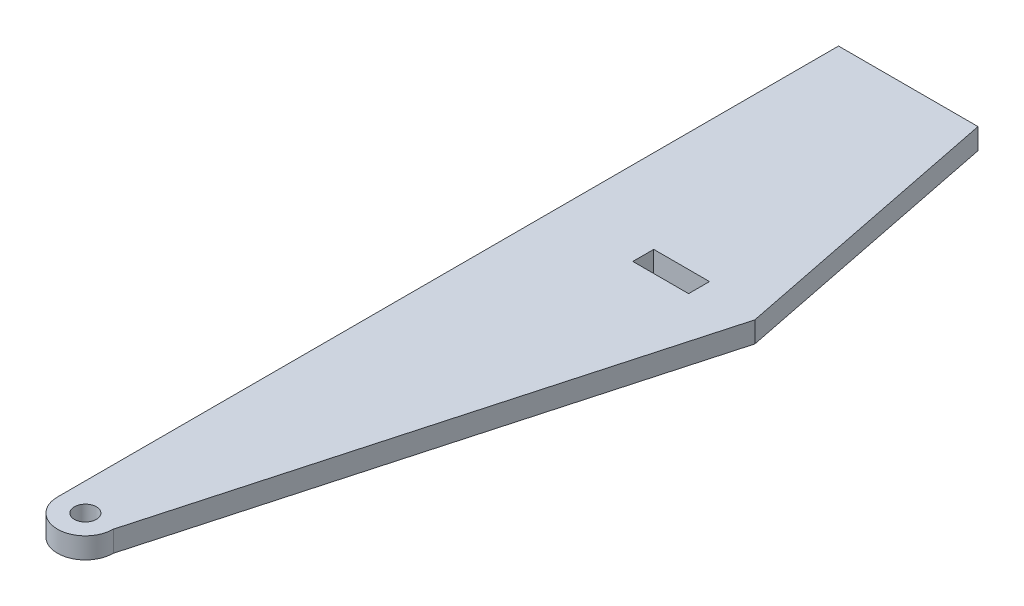
from build123d import *

# Parameters (mm, degrees)
SKETCH1_R           = 10
SKETCH1_W           = 50.8
SKETCH1_H           = 19.05
BOSS_EXTRUDE1_DEPTH = 19.05


with BuildPart() as part:
    # Sketch1 → Boss-Extrude1 (new body)
    with BuildSketch(Plane(origin=(0, 0, 0), x_dir=(1, 0, 0), z_dir=(0, 1, 0))):
        with BuildLine():
            Line((-25.4, 0), (-25.4, 711.2))
            Line((-25.4, 711.2), (101.6, 711.2))
            Line((101.6, 711.2), (152.4, 457.2))
            Line((152.4, 457.2), (25.4, 0))
            ThreePointArc((25.4, 0), (0, -25.4), (-25.4, 0))
        make_face()
        Circle(SKETCH1_R, mode=Mode.SUBTRACT)
        with Locations((76.2, 457.2)):
            Rectangle(SKETCH1_W, SKETCH1_H, mode=Mode.SUBTRACT)
    extrude(amount=BOSS_EXTRUDE1_DEPTH)


solid = part.part
